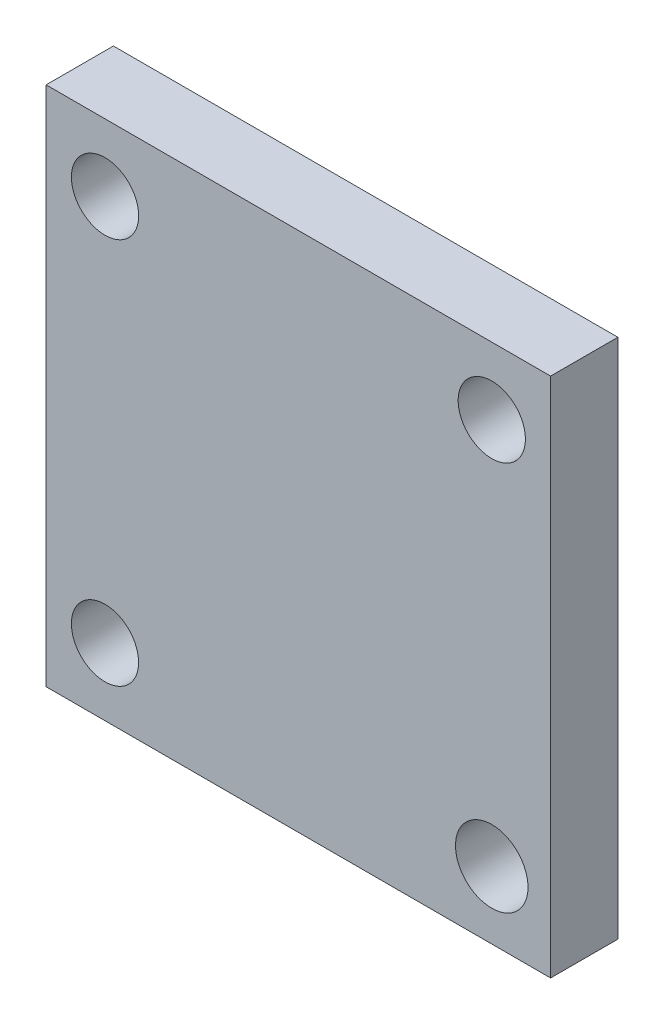
from build123d import *

# Parameters (mm, degrees)
SKETCH2_W           = 30.002183488
SKETCH2_H           = 31.002183488
SKETCH2_R           = 2
SKETCH2_R_2         = 2.156266898
BOSS_EXTRUDE1_DEPTH = 4


with BuildPart() as part:
    # Sketch2 → Boss-Extrude1 (new body)
    with BuildSketch(Plane.XY):
        Rectangle(SKETCH2_W, SKETCH2_H)
        with Locations((-11.498908256, 11.503275233)):
            Circle(SKETCH2_R, mode=Mode.SUBTRACT)
        with Locations((11.503275233, 11.501091744)):
            Circle(SKETCH2_R, mode=Mode.SUBTRACT)
        with Locations((-11.501091744, -11.498908256)):
            Circle(SKETCH2_R, mode=Mode.SUBTRACT)
        with Locations((11.501091744, -11.501091744)):
            Circle(SKETCH2_R_2, mode=Mode.SUBTRACT)
    extrude(amount=BOSS_EXTRUDE1_DEPTH)


solid = part.part
